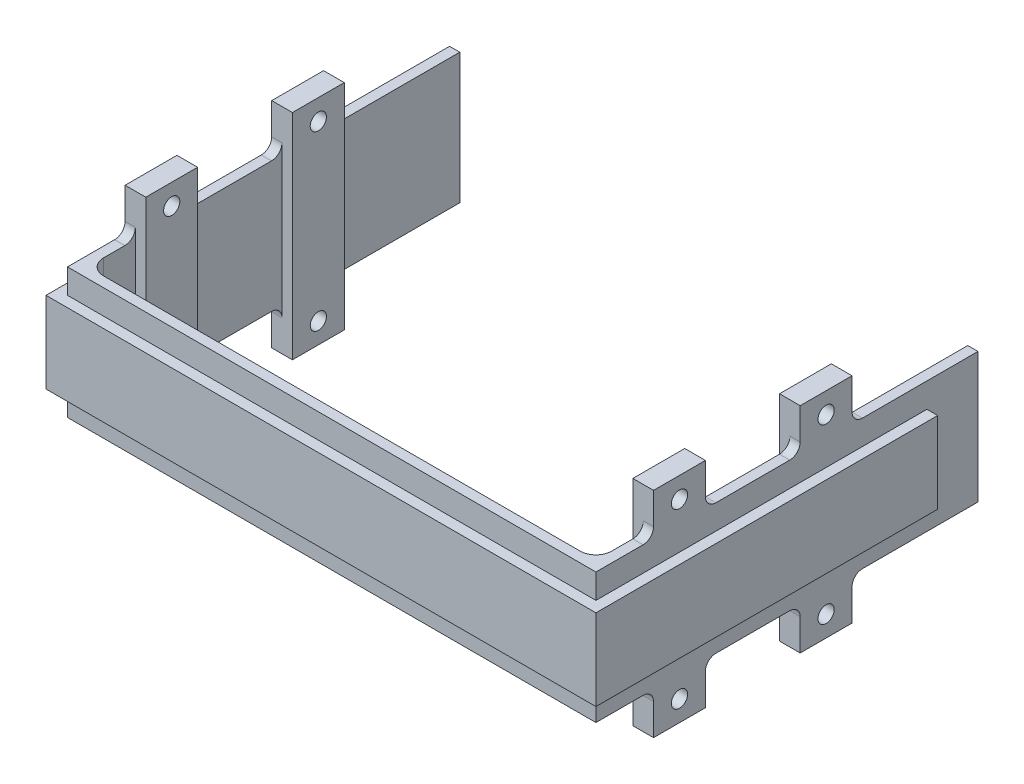
from build123d import *

# Parameters (mm, degrees)
SKETCH1_W                = 1.95
SKETCH1_H                = 9.75
SKETCH1_W_2              = 105
SKETCH1_H_2              = 4
BOSS_EXTRUDE1_DEPTH      = 12.45
SKETCH2_W                = 9.9
SKETCH2_H                = 8
SKETCH2_R                = 1.55
BOSS_EXTRUDE2_DEPTH      = 2
BOSS_EXTRUDE2_DEPTH_BACK = 1.95
BOSS_EXTRUDE3_REACH      = 8
SKETCH3_W                = 9.9
SKETCH3_H                = 24.9
SKETCH4_W                = 9.9
SKETCH4_H                = 8
SKETCH4_R                = 1.55
BOSS_EXTRUDE4_DEPTH      = 2
BOSS_EXTRUDE4_DEPTH_BACK = 1.95
BOSS_EXTRUDE5_REACH      = 8
SKETCH5_W                = 9.9
SKETCH5_H                = 24.9
SKETCH6_W                = 100.9
SKETCH6_H                = 2.05
CUT_EXTRUDE1_DEPTH       = 4.7
SKETCH7_W                = 100.9
SKETCH7_H                = 2.05
CUT_EXTRUDE2_DEPTH       = 4.7
FILLET1_R                = 2
FILLET2_R                = 3


with BuildPart() as part:
    # Sketch1 → Boss-Extrude1 (new body, symmetric)
    with BuildSketch(Plane(origin=(0, 0, 0), x_dir=(1, 0, 0), z_dir=(0, 1, 0))):
        Polygon((-52.5, 63.25), (-52.5, 2), (-48.5, 2), (-48.5, 63.25), (-50.45, 63.25), align=None)
        with Locations((-49.475, 68.125)):
            Rectangle(SKETCH1_W, SKETCH1_H)
        Rectangle(SKETCH1_W_2, SKETCH1_H_2)
        Polygon((48.5, 63.25), (48.5, 2), (52.5, 2), (52.5, 63.25), (50.45, 63.25), align=None)
        with Locations((49.475, 68.125)):
            Rectangle(SKETCH1_W, SKETCH1_H)
    extrude(amount=BOSS_EXTRUDE1_DEPTH, both=True)

    # Sketch2 → Boss-Extrude2 (add, two sides)
    with BuildSketch(Plane.ZY.offset(-48.5)) as boss_extrude2_sk:
        with Locations((-16, -16.45)):
            Rectangle(SKETCH2_W, SKETCH2_H)
        with Locations((-16, -16.5)):
            Circle(SKETCH2_R, mode=Mode.SUBTRACT)
        with Locations((-44, -16.45)):
            Rectangle(SKETCH2_W, SKETCH2_H)
        with Locations((-44, -16.5)):
            Circle(SKETCH2_R, mode=Mode.SUBTRACT)
        with Locations((-16, 16.45)):
            Rectangle(SKETCH2_W, SKETCH2_H)
        with Locations((-16, 16.5)):
            Circle(SKETCH2_R, mode=Mode.SUBTRACT)
        with Locations((-44, 16.45)):
            Rectangle(SKETCH2_W, SKETCH2_H)
        with Locations((-44, 16.5)):
            Circle(SKETCH2_R, mode=Mode.SUBTRACT)
    extrude(amount=BOSS_EXTRUDE2_DEPTH)
    extrude(boss_extrude2_sk.sketch, amount=-BOSS_EXTRUDE2_DEPTH_BACK)

    # Sketch3 → Boss-Extrude3 (add, up to next)
    with BuildSketch(Plane.ZY.offset(-46.5), mode=Mode.PRIVATE) as boss_extrude3_sk1:
        with Locations((-44, 0)):
            Rectangle(SKETCH3_W, SKETCH3_H)
    boss_extrude3_tool1 = extrude(boss_extrude3_sk1.sketch, amount=-BOSS_EXTRUDE3_REACH, mode=Mode.PRIVATE) - part.part
    add(boss_extrude3_tool1.solids().sort_by_distance((46.5, 0, -44))[0])
    # Sketch3 → Boss-Extrude3 (add, up to next)
    with BuildSketch(Plane.ZY.offset(-46.5), mode=Mode.PRIVATE) as boss_extrude3_sk2:
        with Locations((-16, 0)):
            Rectangle(SKETCH3_W, SKETCH3_H)
    boss_extrude3_tool2 = extrude(boss_extrude3_sk2.sketch, amount=-BOSS_EXTRUDE3_REACH, mode=Mode.PRIVATE) - part.part
    add(boss_extrude3_tool2.solids().sort_by_distance((46.5, 0, -16))[0])

    # Sketch4 → Boss-Extrude4 (add, two sides)
    with BuildSketch(Plane(origin=(-48.5, 0, 0), x_dir=(0, 0, -1), z_dir=(1, 0, 0))) as boss_extrude4_sk:
        with Locations((16, 16.45)):
            Rectangle(SKETCH4_W, SKETCH4_H)
        with Locations((16, 16.5)):
            Circle(SKETCH4_R, mode=Mode.SUBTRACT)
        with Locations((44, 16.45)):
            Rectangle(SKETCH4_W, SKETCH4_H)
        with Locations((44, 16.5)):
            Circle(SKETCH4_R, mode=Mode.SUBTRACT)
        with Locations((44, -16.45)):
            Rectangle(SKETCH4_W, SKETCH4_H)
        with Locations((44, -16.5)):
            Circle(SKETCH4_R, mode=Mode.SUBTRACT)
        with Locations((16, -16.45)):
            Rectangle(SKETCH4_W, SKETCH4_H)
        with Locations((16, -16.5)):
            Circle(SKETCH4_R, mode=Mode.SUBTRACT)
    extrude(amount=BOSS_EXTRUDE4_DEPTH)
    extrude(boss_extrude4_sk.sketch, amount=-BOSS_EXTRUDE4_DEPTH_BACK)

    # Sketch5 → Boss-Extrude5 (add, up to next)
    with BuildSketch(Plane(origin=(-46.5, 0, 0), x_dir=(0, 0, -1), z_dir=(1, 0, 0)), mode=Mode.PRIVATE) as boss_extrude5_sk1:
        with Locations((16, 0)):
            Rectangle(SKETCH5_W, SKETCH5_H)
    boss_extrude5_tool1 = extrude(boss_extrude5_sk1.sketch, amount=-BOSS_EXTRUDE5_REACH, mode=Mode.PRIVATE) - part.part
    add(boss_extrude5_tool1.solids().sort_by_distance((-46.5, 0, -16))[0])
    # Sketch5 → Boss-Extrude5 (add, up to next)
    with BuildSketch(Plane(origin=(-46.5, 0, 0), x_dir=(0, 0, -1), z_dir=(1, 0, 0)), mode=Mode.PRIVATE) as boss_extrude5_sk2:
        with Locations((44, 0)):
            Rectangle(SKETCH5_W, SKETCH5_H)
    boss_extrude5_tool2 = extrude(boss_extrude5_sk2.sketch, amount=-BOSS_EXTRUDE5_REACH, mode=Mode.PRIVATE) - part.part
    add(boss_extrude5_tool2.solids().sort_by_distance((-46.5, 0, -44))[0])

    # Sketch6 → Cut-Extrude1 (cut)
    with BuildSketch(Plane.XZ.offset(12.45)):
        with Locations((0, 0.975)):
            Rectangle(SKETCH6_W, SKETCH6_H)
        Polygon((50.45, 2), (50.45, -0.05), (50.45, -63.25), (52.5, -63.25), (52.5, 2), align=None)
        Polygon((-52.5, -63.25), (-50.45, -63.25), (-50.45, -0.05), (-50.45, 2), (-52.5, 2), align=None)
    extrude(amount=-CUT_EXTRUDE1_DEPTH, mode=Mode.SUBTRACT)

    # Sketch7 → Cut-Extrude2 (cut)
    with BuildSketch(Plane(origin=(0, 12.45, 0), x_dir=(1, 0, 0), z_dir=(0, 1, 0))):
        Polygon((-50.45, 48.95), (-50.45, 63.25), (-52.5, 63.25), (-52.5, -2), (-50.45, -2), (-50.45, 0.05), (-50.45, 11.05), (-50.45, 20.95), (-50.45, 39.05), align=None)
        with Locations((0, -0.975)):
            Rectangle(SKETCH7_W, SKETCH7_H)
        Polygon((50.45, 0.05), (50.45, -2), (52.5, -2), (52.5, 63.25), (50.45, 63.25), (50.45, 48.95), (50.45, 39.05), (50.45, 20.95), (50.45, 11.05), align=None)
    extrude(amount=-CUT_EXTRUDE2_DEPTH, mode=Mode.SUBTRACT)

    # Fillet1
    fillet1_edges = [part.edges().sort_by_distance(p)[0] for p in [
        (-49.475, 12.45, -11.05),
        (-49.475, 12.45, -20.95),
        (-49.475, 12.45, -39.05),
        (-49.475, 12.45, -48.95),
        (-49.475, -12.45, -39.05),
        (-49.475, -12.45, -48.95),
        (-49.475, -12.45, -11.05),
        (-49.475, -12.45, -20.95),
        (49.475, -12.45, -20.95),
        (49.475, -12.45, -11.05),
        (49.475, -12.45, -48.95),
        (49.475, -12.45, -39.05),
        (49.475, 12.45, -11.05),
        (49.475, 12.45, -20.95),
        (49.475, 12.45, -48.95),
        (49.475, 12.45, -39.05),
    ]]
    fillet(fillet1_edges, radius=FILLET1_R)

    # Fillet2
    fillet2_edges = [part.edges().sort_by_distance(p)[0] for p in [
        (-48.5, 0, -2),
        (48.5, 0, -2),
    ]]
    fillet(fillet2_edges, radius=FILLET2_R)


solid = part.part
